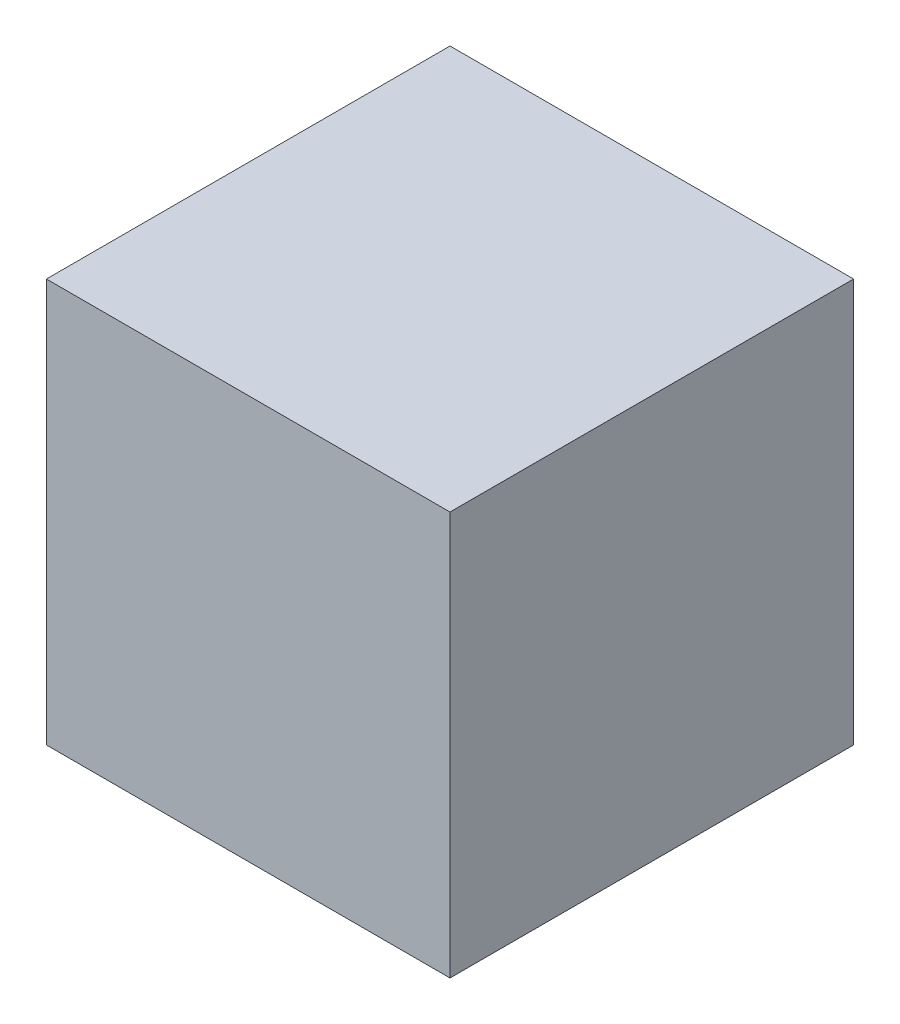
from build123d import *

# Parameters (mm, degrees)
ESBO_O1_W                = 240.83
ESBO_O1_H                = 240.83
RESSALTO_EXTRUS_O1_DEPTH = 120.415


with BuildPart() as part:
    # Esboço1 → Ressalto-extrusão1 (new body, symmetric)
    with BuildSketch(Plane.XY):
        Rectangle(ESBO_O1_W, ESBO_O1_H)
    extrude(amount=RESSALTO_EXTRUS_O1_DEPTH, both=True)


solid = part.part
